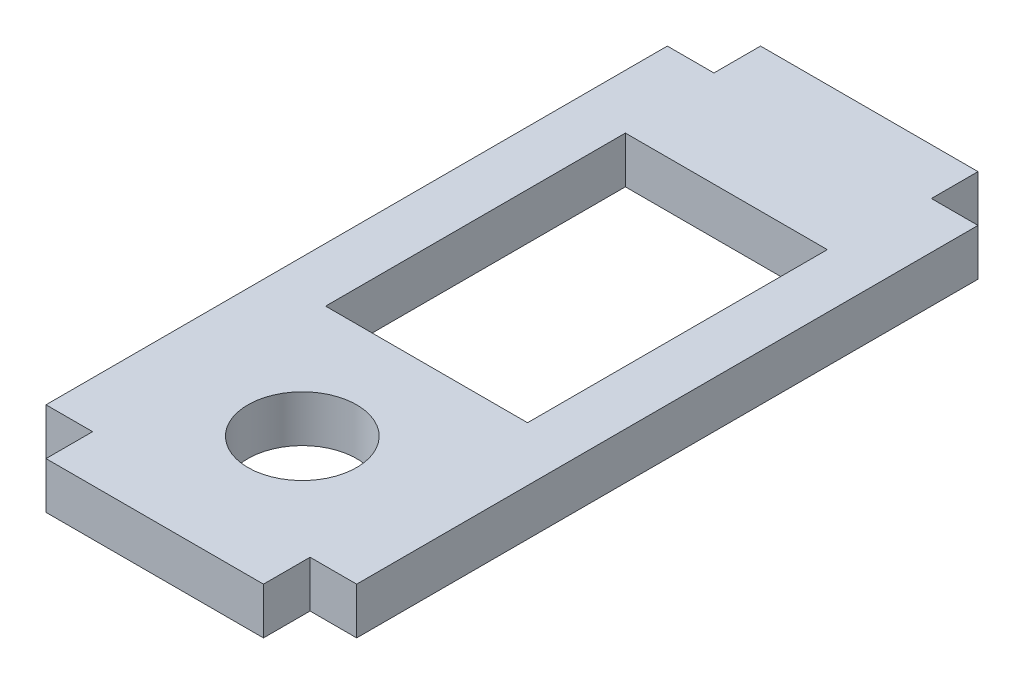
from build123d import *

# Parameters (mm, degrees)
SKETCH1_R           = 3.5
SKETCH1_W           = 13
SKETCH1_H           = 19.3
BOSS_EXTRUDE1_DEPTH = 3


with BuildPart() as part:
    # Sketch1 → Boss-Extrude1 (new body)
    with BuildSketch(Plane(origin=(0, 0, 0), x_dir=(1, 0, 0), z_dir=(0, 1, 0))):
        Polygon((7, 20), (10, 20), (10, -20), (7, -20), (7, -23), (-7, -23), (-7, -20), (-10, -20), (-10, 20), (-7, 20), (-7, 23), (7, 23), align=None)
        with Locations((0, -13.5)):
            Circle(SKETCH1_R, mode=Mode.SUBTRACT)
        with Locations((0, 4.15)):
            Rectangle(SKETCH1_W, SKETCH1_H, mode=Mode.SUBTRACT)
    extrude(amount=BOSS_EXTRUDE1_DEPTH)


solid = part.part
